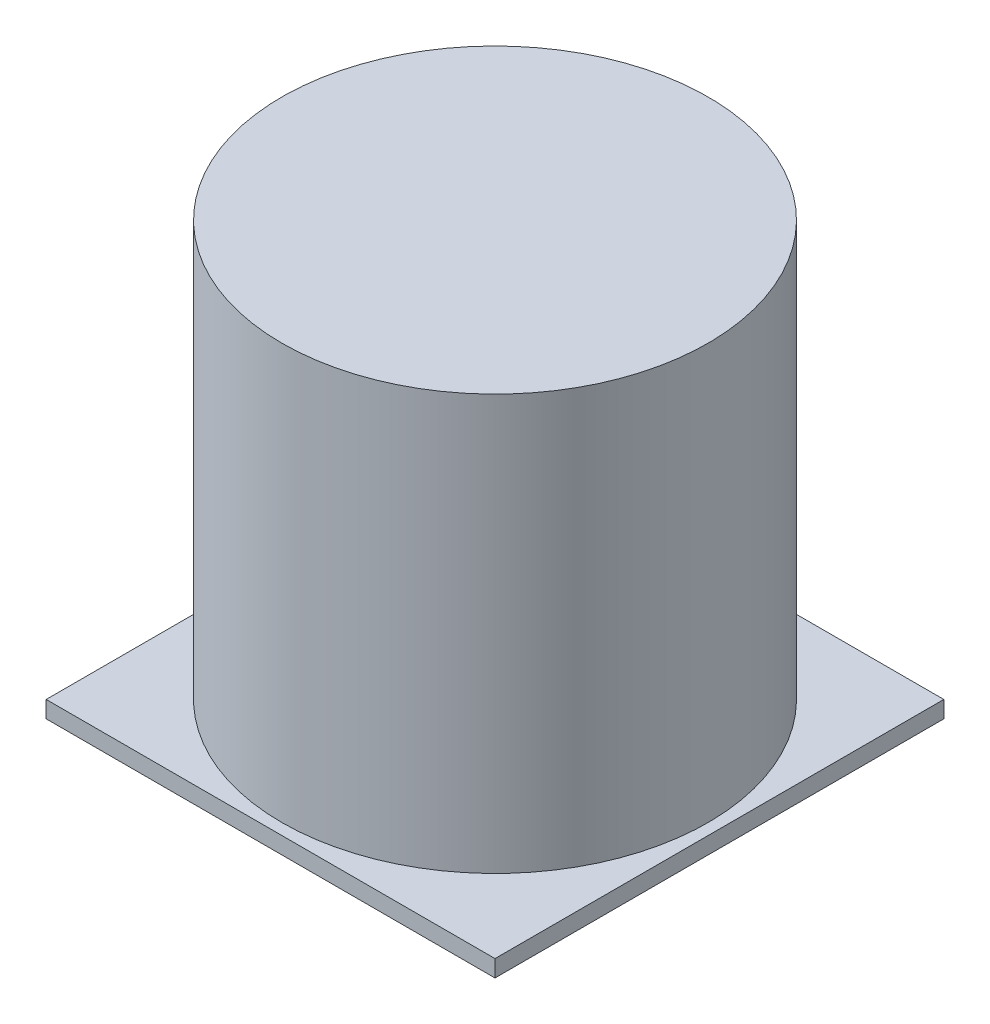
from build123d import *

# Parameters (mm, degrees)
SKETCH1_W           = 80
SKETCH1_H           = 80
BOSS_EXTRUDE1_DEPTH = 3
SKETCH3_R           = 38
SKETCH3_R_2         = 35
EXTRUDE_THIN1_DEPTH = 74


with BuildPart() as part:
    # Sketch1 → Boss-Extrude1 (new body)
    with BuildSketch(Plane(origin=(0, 0, 0), x_dir=(1, 0, 0), z_dir=(0, 1, 0))):
        with Locations((40, 0)):
            Rectangle(SKETCH1_W, SKETCH1_H)
    extrude(amount=BOSS_EXTRUDE1_DEPTH)

    # Sketch3 → Extrude-Thin1 (add)
    with BuildSketch(Plane(origin=(0, 3, 0), x_dir=(1, 0, 0), z_dir=(0, 1, 0))):
        with Locations((40, 0)):
            Circle(SKETCH3_R)
        with Locations((40, 0)):
            Circle(SKETCH3_R_2, mode=Mode.SUBTRACT)
    extrude(amount=EXTRUDE_THIN1_DEPTH)

    # Sketch7 → Revolve5 (revolve)
    with BuildSketch(Plane.XY):
        Polygon((40, 77), (2, 77), (2, 36), (40, 74), align=None)
    revolve(axis=Axis((40, 77, 0), (0, -1, 0)))


solid = part.part
